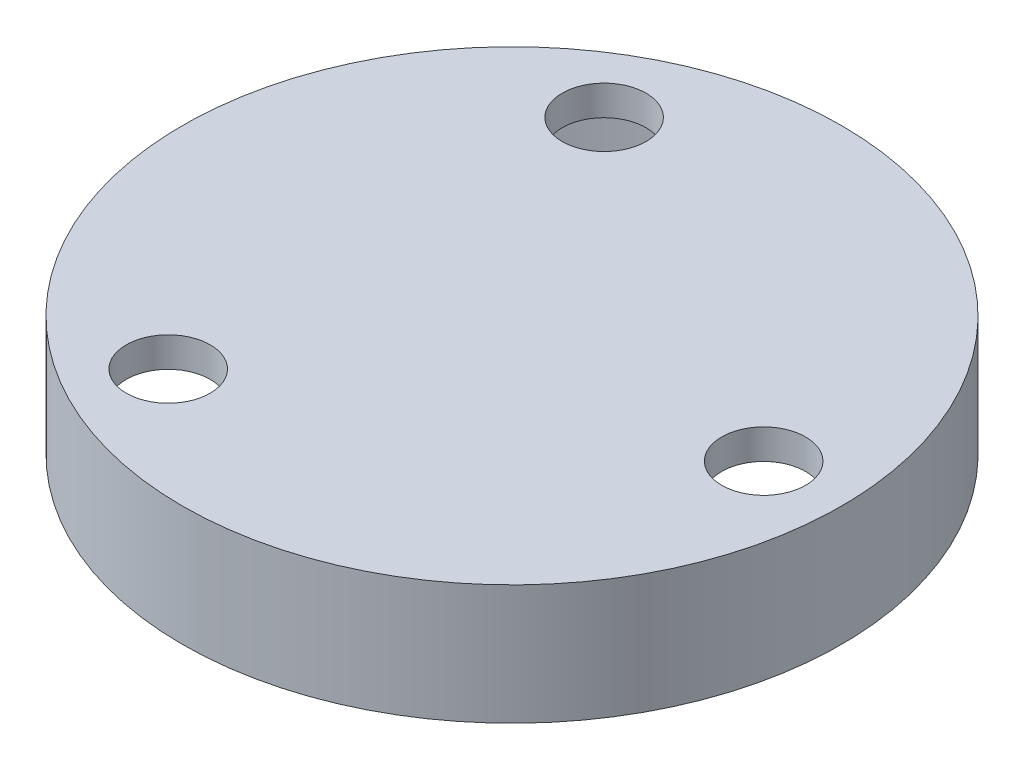
from build123d import *

# Parameters (mm, degrees)
SKETCH2_R                    = 55
SKETCH2_R_2                  = 50
BOSS_EXTRUDE1_DEPTH          = 20
SKETCH3_R                    = 55
BOSS_EXTRUDE2_DEPTH          = 5
TAP_DRILL_FOR_M14X2_0_TAP1_D = 14
CIRPATTERN1_COUNT            = 3


with BuildPart() as part:
    # Sketch2 → Boss-Extrude1 (new body)
    with BuildSketch(Plane(origin=(0, 0, 0), x_dir=(1, 0, 0), z_dir=(0, 1, 0))):
        Circle(SKETCH2_R)
        Circle(SKETCH2_R_2, mode=Mode.SUBTRACT)
    extrude(amount=-BOSS_EXTRUDE1_DEPTH)

    # Sketch3 → Boss-Extrude2 (add)
    with BuildSketch(Plane(origin=(0, 0, 0), x_dir=(1, 0, 0), z_dir=(0, 1, 0))):
        Circle(SKETCH3_R)
    extrude(amount=-BOSS_EXTRUDE2_DEPTH)

    # Tap Drill for M14x2.0 Tap1 (through all)
    with Locations(Plane(origin=(0, 0, 0), x_dir=(1, 0, 0), z_dir=(0, 1, 0))):
        with Locations((42, 0)):
            tap_drill_for_m14x2_0_tap1 = Hole(TAP_DRILL_FOR_M14X2_0_TAP1_D / 2)

    # CirPattern1: Tap Drill for M14x2.0 Tap1 ×3 about axis
    cirpattern1_axis = Axis((0, -21, 0), (0, 1, 0))
    for i in range(1, CIRPATTERN1_COUNT):
        add(tap_drill_for_m14x2_0_tap1.rotate(cirpattern1_axis, i * 360 / CIRPATTERN1_COUNT), mode=Mode.SUBTRACT)


solid = part.part
